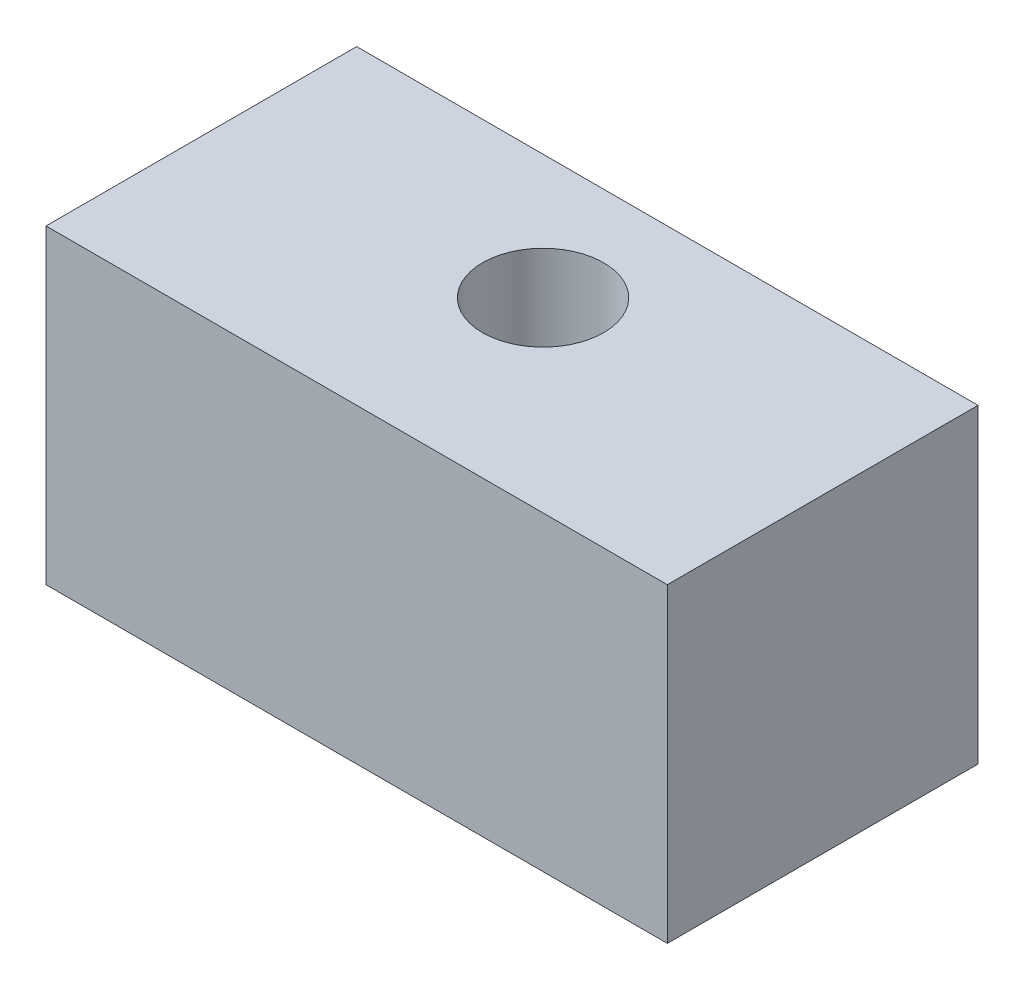
from build123d import *

# Parameters (mm, degrees)
SKETCH3_W           = 20
SKETCH3_H           = 10
BOSS_EXTRUDE1_DEPTH = 10
SKETCH4_R           = 1.95
CUT_EXTRUDE1_DEPTH  = 10


with BuildPart() as part:
    # Sketch3 → Boss-Extrude1 (new body)
    with BuildSketch(Plane(origin=(0, 0, 0), x_dir=(1, 0, 0), z_dir=(0, 1, 0))):
        Rectangle(SKETCH3_W, SKETCH3_H)
    extrude(amount=BOSS_EXTRUDE1_DEPTH)

    # Sketch4 → Cut-Extrude1 (cut)
    with BuildSketch(Plane(origin=(0, 10, 0), x_dir=(1, 0, 0), z_dir=(0, 1, 0))):
        with Locations((0, 1)):
            Circle(SKETCH4_R)
    extrude(amount=-CUT_EXTRUDE1_DEPTH, mode=Mode.SUBTRACT)


solid = part.part
